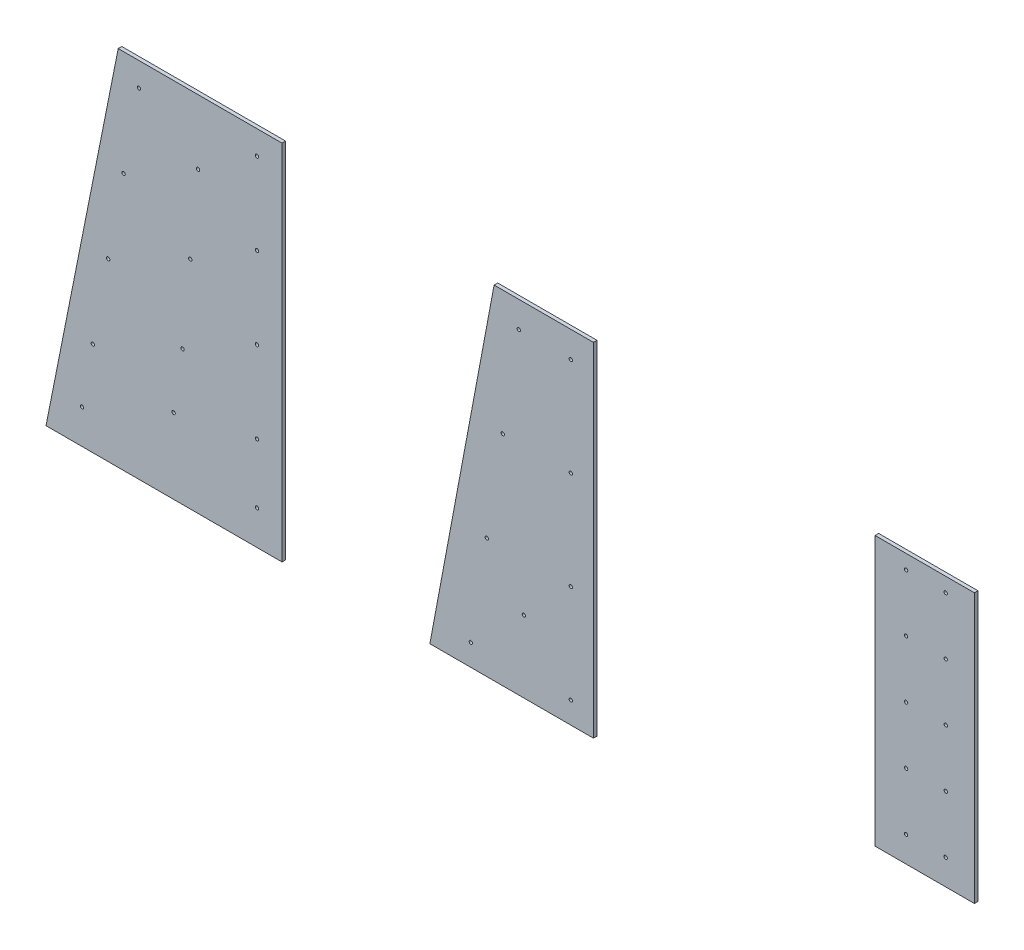
from build123d import *

# Parameters (mm, degrees)
IZIM1_R                       = 7
Y_KSEKLIK_EKSTR_ZYON1_DEPTH   = 15
Y_KSEKLIK_EKSTR_ZYON1_2_DEPTH = 15
Y_KSEKLIK_EKSTR_ZYON1_3_DEPTH = 15


with BuildPart() as part:
    # Çizim1 → Yükseklik-Ekstrüzyon1 (new body)
    with BuildSketch(Plane.XY):
        Polygon((-17083.890627452, -24311.586231701), (-17770.377761234, -24311.586231701), (-18072.972325265, -25831.586231701), (-17083.890627452, -25831.586231701), align=None)
        with Locations((-17747.807648973, -24753.601134834)):
            Circle(IZIM1_R, mode=Mode.SUBTRACT)
        with Locations((-17812.495649489, -25095.616037966)):
            Circle(IZIM1_R, mode=Mode.SUBTRACT)
        with Locations((-17877.183650005, -25437.630941098)):
            Circle(IZIM1_R, mode=Mode.SUBTRACT)
        with Locations((-17436.005137954, -24582.593683268)):
            Circle(IZIM1_R, mode=Mode.SUBTRACT)
        with Locations((-17188.890627452, -24753.601134834)):
            Circle(IZIM1_R, mode=Mode.SUBTRACT)
        with Locations((-17188.890627452, -25095.616037966)):
            Circle(IZIM1_R, mode=Mode.SUBTRACT)
        with Locations((-17188.890627452, -25437.630941098)):
            Circle(IZIM1_R, mode=Mode.SUBTRACT)
        with Locations((-17683.119648456, -24411.586231701)):
            Circle(IZIM1_R, mode=Mode.SUBTRACT)
        with Locations((-17468.349138212, -24924.6085864)):
            Circle(IZIM1_R, mode=Mode.SUBTRACT)
        with Locations((-17500.693138471, -25266.623489532)):
            Circle(IZIM1_R, mode=Mode.SUBTRACT)
        with Locations((-17188.890627452, -24411.586231701)):
            Circle(IZIM1_R, mode=Mode.SUBTRACT)
        with Locations((-17922.300414307, -25687.630941098)):
            Circle(IZIM1_R, mode=Mode.SUBTRACT)
        with Locations((-17188.890627452, -25687.630941098)):
            Circle(IZIM1_R, mode=Mode.SUBTRACT)
        with Locations((-17538.120122273, -25516.623489532)):
            Circle(IZIM1_R, mode=Mode.SUBTRACT)
    extrude(amount=Y_KSEKLIK_EKSTR_ZYON1_DEPTH)


with BuildPart() as body_2:
    # Çizim1 → Y_kseklik-Ekstr_zyon1 2 (new body)
    with BuildSketch(Plane.XY):
        Polygon((-16464.462886753, -25818.590408101), (-16195.346585806, -24382.229116616), (-15779.113039081, -24382.14430812), (-15779.113039081, -25818.590408101), align=None)
        with Locations((-16158.922915355, -24904.033031627)):
            Circle(IZIM1_R, mode=Mode.SUBTRACT)
        with Locations((-16225.920281535, -25315.921755134)):
            Circle(IZIM1_R, mode=Mode.SUBTRACT)
        with Locations((-16292.917647714, -25727.810478641)):
            Circle(IZIM1_R, mode=Mode.SUBTRACT)
        with Locations((-15874.113039081, -25727.810478641)):
            Circle(IZIM1_R, mode=Mode.SUBTRACT)
        with Locations((-15874.113039081, -25315.921755134)):
            Circle(IZIM1_R, mode=Mode.SUBTRACT)
        with Locations((-15874.113039081, -24904.033031627)):
            Circle(IZIM1_R, mode=Mode.SUBTRACT)
        with Locations((-16091.925549176, -24492.14430812)):
            Circle(IZIM1_R, mode=Mode.SUBTRACT)
        with Locations((-15874.113039081, -24492.14430812)):
            Circle(IZIM1_R, mode=Mode.SUBTRACT)
        with Locations((-16070.545892819, -25517.746737664)):
            Circle(IZIM1_R, mode=Mode.SUBTRACT)
    extrude(amount=Y_KSEKLIK_EKSTR_ZYON1_2_DEPTH)


with BuildPart() as body_3:
    # Çizim1 → Y_kseklik-Ekstr_zyon1 3 (new body)
    with BuildSketch(Plane.XY):
        Polygon((-14182.742851617, -24492.85585625), (-14182.672332855, -25620.356067558), (-14598.934322667, -25620.3816471), (-14599.005313652, -24492.881435822), align=None)
        with Locations((-14469.005313652, -24552.881435822)):
            Circle(IZIM1_R, mode=Mode.SUBTRACT)
        with Locations((-14302.742851617, -24552.881435822)):
            Circle(IZIM1_R, mode=Mode.SUBTRACT)
        with Locations((-14469.005313652, -24792.881435822)):
            Circle(IZIM1_R, mode=Mode.SUBTRACT)
        with Locations((-14302.742851617, -24792.881435822)):
            Circle(IZIM1_R, mode=Mode.SUBTRACT)
        with Locations((-14469.005313652, -25032.881435822)):
            Circle(IZIM1_R, mode=Mode.SUBTRACT)
        with Locations((-14302.742851617, -25032.881435822)):
            Circle(IZIM1_R, mode=Mode.SUBTRACT)
        with Locations((-14469.005313652, -25272.881435822)):
            Circle(IZIM1_R, mode=Mode.SUBTRACT)
        with Locations((-14302.742851617, -25272.881435822)):
            Circle(IZIM1_R, mode=Mode.SUBTRACT)
        with Locations((-14469.005313652, -25512.881435822)):
            Circle(IZIM1_R, mode=Mode.SUBTRACT)
        with Locations((-14302.742851617, -25512.881435822)):
            Circle(IZIM1_R, mode=Mode.SUBTRACT)
    extrude(amount=Y_KSEKLIK_EKSTR_ZYON1_3_DEPTH)


solid = Compound([part.part, body_2.part, body_3.part])
